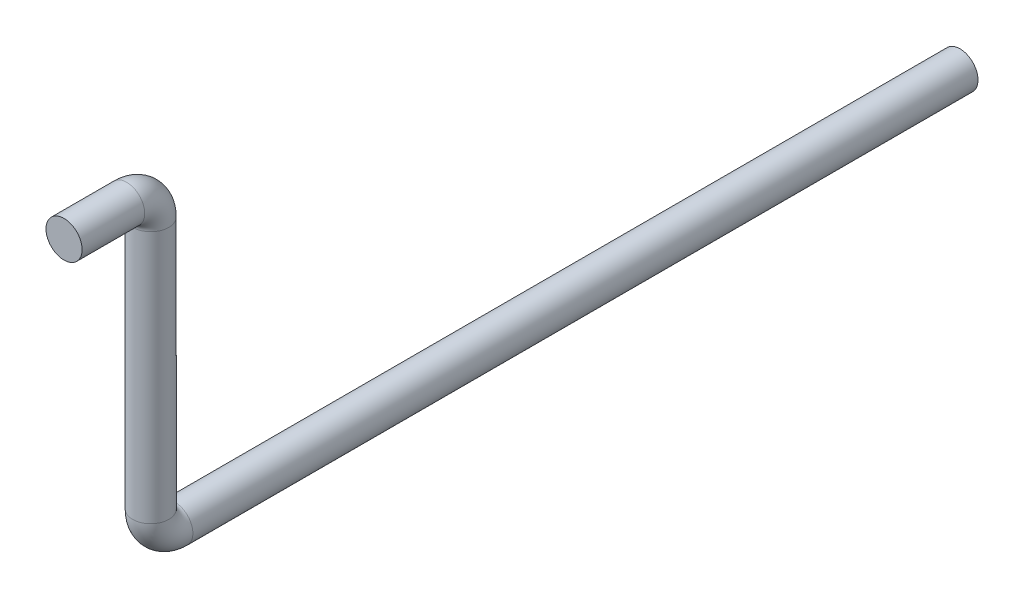
from build123d import *

# Parameters (mm, degrees)
CROQUIS1_R              = 7.5
CROQUIS2_R              = 7.5
SALIENTE_EXTRUIR1_DEPTH = 300


with BuildPart() as part:
    # Barrer1: sweep along a curve in space
    with BuildLine() as barrer1_path:
        Line((4.693833182, 15.151479833, 0), (4.693833182, 15.151479833, 26))
        ThreePointArc((4.693833182, 15.151479833, 26), (4.693833182, 18.080412022, 33.071067812), (4.693833182, 25.151479833, 36))
        Line((4.693833182, 25.151479833, 36), (4.693833182, 130.151479833, 36))
        ThreePointArc((4.693833182, 130.151479833, 36), (4.693833182, 137.222547645, 38.928932188), (4.693833182, 140.151479833, 46))
        Line((4.693833182, 140.151479833, 46), (4.693833182, 140.151479833, 72))
    # Croquis1 → Barrer1 (sweep)
    with BuildSketch(Plane.XY):
        with Locations((4.693833182, 15.151479833)):
            Circle(CROQUIS1_R)
    sweep(path=barrer1_path.line)

    # Croquis2 → Saliente-Extruir1 (add)
    with BuildSketch(Plane(origin=(0, 0, 0), x_dir=(-1, 0, 0), z_dir=(0, 0, -1))):
        with Locations((-4.693833182, 15.151479833)):
            Circle(CROQUIS2_R)
    extrude(amount=SALIENTE_EXTRUIR1_DEPTH)


solid = part.part
